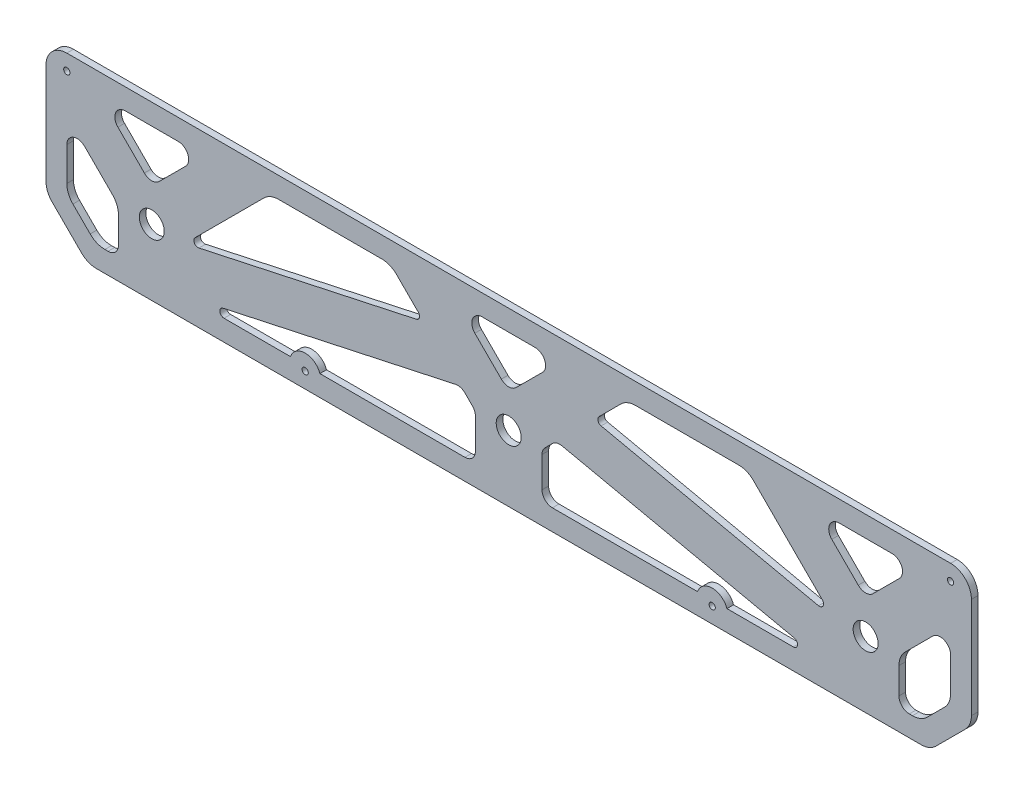
from build123d import *

# Parameters (mm, degrees)
SKETCH1_R           = 1.5
SKETCH1_R_2         = 5.999572562
SKETCH1_R_3         = 6
BOSS_EXTRUDE1_DEPTH = 3.175
FILLET1_R           = 10
FILLET2_R           = 5
FILLET3_R           = 5
FILLET4_R           = 5
FILLET5_R           = 2
SKETCH2_R           = 1.55
SKETCH2_R_2         = 10.9982
BOSS_EXTRUDE2_DEPTH = 3.175
FILLET6_R           = 10
SKETCH3_W           = 432.103191494
SKETCH3_H           = 125.929831314
CUT_EXTRUDE1_DEPTH  = 10


with BuildPart() as part:
    # Sketch1 → Boss-Extrude1 (new body)
    with BuildSketch(Plane.XY):
        with BuildLine():
            ThreePointArc((0, 24.142135624), (0.761204675, 20.3153013), (2.928932188, 17.071067812))
            Line((2.928932188, 17.071067812), (17.071067812, 2.928932188))
            ThreePointArc((17.071067812, 2.928932188), (20.3153013, 0.761204675), (24.142135624, 0))
            Line((24.142135624, 0), (420.357864376, 0))
            ThreePointArc((420.357864376, 0), (424.1846987, 0.761204675), (427.428932188, 2.928932188))
            Line((427.428932188, 2.928932188), (441.571067812, 17.071067812))
            ThreePointArc((441.571067812, 17.071067812), (443.738795325, 20.3153013), (444.5, 24.142135624))
            Line((444.5, 24.142135624), (444.5, 72.55))
            ThreePointArc((444.5, 72.55), (441.571067812, 79.621067812), (434.5, 82.55))
            Line((434.5, 82.55), (10, 82.55))
            ThreePointArc((10, 82.55), (2.928932188, 79.621067812), (0, 72.55))
            Line((0, 72.55), (0, 24.142135624))
        make_face()
        with Locations((124.487832174, 7.5)):
            Circle(SKETCH1_R, mode=Mode.SUBTRACT)
        with BuildLine():
            ThreePointArc((12.928932188, 21.213203436), (10.761204675, 24.457436924), (10, 28.284271247))
            Line((10, 28.284271247), (10, 56.550427438))
            Line((10, 56.550427438), (34.800427438, 31.75))
            Line((34.800427438, 31.75), (34.800427438, 10))
            Line((34.800427438, 10), (28.284271247, 10))
            ThreePointArc((28.284271247, 10), (24.457436924, 10.761204675), (21.213203436, 12.928932188))
            Line((21.213203436, 12.928932188), (12.928932188, 21.213203436))
        make_face(mode=Mode.SUBTRACT)
        with Locations((50.8, 31.75)):
            Circle(SKETCH1_R_2, mode=Mode.SUBTRACT)
        with BuildLine():
            Line((199.331464685, 38.668535315), (206.25, 31.75))
            Line((206.25, 31.75), (206.25, 10))
            Line((206.25, 10), (131.558899986, 10))
            ThreePointArc((131.558899986, 10), (124.487832174, 15), (117.416764362, 10))
            Line((117.416764362, 10), (66.799572562, 10))
            Line((66.799572562, 10), (199.331464685, 38.668535315))
        make_face(mode=Mode.SUBTRACT)
        with Locations((320.012167826, 7.5)):
            Circle(SKETCH1_R, mode=Mode.SUBTRACT)
        with BuildLine():
            Line((238.25, 10), (238.25, 31.75))
            Line((238.25, 31.75), (245.168535315, 38.668535315))
            Line((245.168535315, 38.668535315), (377.700427438, 10))
            Line((377.700427438, 10), (327.083235638, 10))
            ThreePointArc((327.083235638, 10), (320.012167826, 15), (312.941100014, 10))
            Line((312.941100014, 10), (238.25, 10))
        make_face(mode=Mode.SUBTRACT)
        with Locations((222.25, 31.75)):
            Circle(SKETCH1_R_3, mode=Mode.SUBTRACT)
        with Locations((393.7, 31.75)):
            Circle(SKETCH1_R_2, mode=Mode.SUBTRACT)
        with BuildLine():
            Line((434.5, 56.550427438), (434.5, 28.284271247))
            ThreePointArc((434.5, 28.284271247), (433.738795325, 24.457436924), (431.571067812, 21.213203436))
            Line((431.571067812, 21.213203436), (423.286796564, 12.928932188))
            ThreePointArc((423.286796564, 12.928932188), (420.042563076, 10.761204675), (416.215728753, 10))
            Line((416.215728753, 10), (409.699572562, 10))
            Line((409.699572562, 10), (409.699572562, 31.75))
            Line((409.699572562, 31.75), (434.5, 56.550427438))
        make_face(mode=Mode.SUBTRACT)
        Polygon((50.8, 47.749572562), (25.999572562, 72.55), (75.600427438, 72.55), align=None, mode=Mode.SUBTRACT)
        Polygon((181.449572562, 56.550427438), (66.799572562, 31.75), (107.599572562, 72.55), (165.45, 72.55), align=None, mode=Mode.SUBTRACT)
        Polygon((247.05, 72.55), (222.25, 47.75), (197.45, 72.55), align=None, mode=Mode.SUBTRACT)
        with Locations((10, 75.05)):
            Circle(SKETCH1_R, mode=Mode.SUBTRACT)
        Polygon((263.050427438, 56.550427438), (279.05, 72.55), (336.900427438, 72.55), (377.700427438, 31.75), align=None, mode=Mode.SUBTRACT)
        Polygon((418.500427438, 72.55), (393.7, 47.749572562), (368.899572562, 72.55), align=None, mode=Mode.SUBTRACT)
        with Locations((434.5, 75.05)):
            Circle(SKETCH1_R, mode=Mode.SUBTRACT)
    extrude(amount=BOSS_EXTRUDE1_DEPTH)

    # Fillet1
    fillet1_edges = [part.edges().sort_by_distance(p)[0] for p in [
        (34.800427438, 31.75, 1.5875),
        (409.699572562, 31.75, 1.5875),
        (336.900427438, 72.55, 1.5875),
        (279.05, 72.55, 1.5875),
        (165.45, 72.55, 1.5875),
        (107.599572562, 72.55, 1.5875),
    ]]
    fillet(fillet1_edges, radius=FILLET1_R)

    # Fillet2
    fillet2_edges = [part.edges().sort_by_distance(p)[0] for p in [
        (245.168535315, 38.668535315, 1.5875),
        (238.25, 31.75, 1.5875),
        (238.25, 10, 1.5875),
        (34.800427438, 10, 1.5875),
        (409.699572562, 10, 1.5875),
        (206.25, 10, 1.5875),
        (206.25, 31.75, 1.5875),
        (199.331464685, 38.668535315, 1.5875),
    ]]
    fillet(fillet2_edges, radius=FILLET2_R)

    # Fillet3
    fillet3_edges = [part.edges().sort_by_distance(p)[0] for p in [
        (222.25, 47.75, 1.5875),
        (247.05, 72.55, 1.5875),
        (197.45, 72.55, 1.5875),
    ]]
    fillet(fillet3_edges, radius=FILLET3_R)

    # Fillet4
    fillet4_edges = [part.edges().sort_by_distance(p)[0] for p in [
        (10, 56.550427438, 1.5875),
        (434.5, 56.550427438, 1.5875),
        (75.600427438, 72.55, 1.5875),
        (25.999572562, 72.55, 1.5875),
        (50.8, 47.749572562, 1.5875),
        (393.7, 47.749572562, 1.5875),
        (418.500427438, 72.55, 1.5875),
        (368.899572562, 72.55, 1.5875),
    ]]
    fillet(fillet4_edges, radius=FILLET4_R)

    # Fillet5
    fillet5_edges = [part.edges().sort_by_distance(p)[0] for p in [
        (377.700427438, 10, 1.5875),
        (377.700427438, 31.75, 1.5875),
        (263.050427438, 56.550427438, 1.5875),
        (66.799572562, 31.75, 1.5875),
        (181.449572562, 56.550427438, 1.5875),
        (66.799572562, 10, 1.5875),
    ]]
    fillet(fillet5_edges, radius=FILLET5_R)

    # Sketch2 → Boss-Extrude2 (add)
    with BuildSketch(Plane.XY.offset(3.175)):
        with BuildLine():
            Line((135.175, 104.55), (135.175, 82.55))
            Line((135.175, 82.55), (97.075, 82.55))
            Line((97.075, 82.55), (97.075, 104.55))
            ThreePointArc((97.075, 104.55), (116.125, 123.6), (135.175, 104.55))
        make_face()
        with Locations((130.1204, 104.55)):
            Circle(SKETCH2_R, mode=Mode.SUBTRACT)
        with Locations((116.125, 90.5546)):
            Circle(SKETCH2_R, mode=Mode.SUBTRACT)
        with Locations((102.1296, 104.55)):
            Circle(SKETCH2_R, mode=Mode.SUBTRACT)
        with Locations((116.125, 118.5454)):
            Circle(SKETCH2_R, mode=Mode.SUBTRACT)
        with Locations((116.125, 104.55)):
            Circle(SKETCH2_R_2, mode=Mode.SUBTRACT)
        with BuildLine():
            ThreePointArc((309.325, 104.55), (328.375, 123.6), (347.425, 104.55))
            Line((347.425, 104.55), (347.425, 82.55))
            Line((347.425, 82.55), (309.325, 82.55))
            Line((309.325, 82.55), (309.325, 104.55))
        make_face()
        with Locations((328.375, 118.5454)):
            Circle(SKETCH2_R, mode=Mode.SUBTRACT)
        with Locations((328.375, 90.5546)):
            Circle(SKETCH2_R, mode=Mode.SUBTRACT)
        with Locations((314.3796, 104.55)):
            Circle(SKETCH2_R, mode=Mode.SUBTRACT)
        with Locations((342.3704, 104.55)):
            Circle(SKETCH2_R, mode=Mode.SUBTRACT)
        with Locations((328.375, 104.55)):
            Circle(SKETCH2_R_2, mode=Mode.SUBTRACT)
    extrude(amount=-BOSS_EXTRUDE2_DEPTH)

    # Fillet6
    fillet6_edges = [part.edges().sort_by_distance(p)[0] for p in [
        (135.175, 82.55, 1.5875),
        (97.075, 82.55, 1.5875),
        (347.425, 82.55, 1.5875),
        (309.325, 82.55, 1.5875),
    ]]
    fillet(fillet6_edges, radius=FILLET6_R)

    # Sketch3 → Cut-Extrude1 (cut)
    with BuildSketch(Plane(origin=(0, 0, 0), x_dir=(-1, 0, 0), z_dir=(0, 0, -1))):
        with Locations((-252.22532491, 145.514915657)):
            Rectangle(SKETCH3_W, SKETCH3_H)
    extrude(amount=-CUT_EXTRUDE1_DEPTH, mode=Mode.SUBTRACT)


solid = part.part
